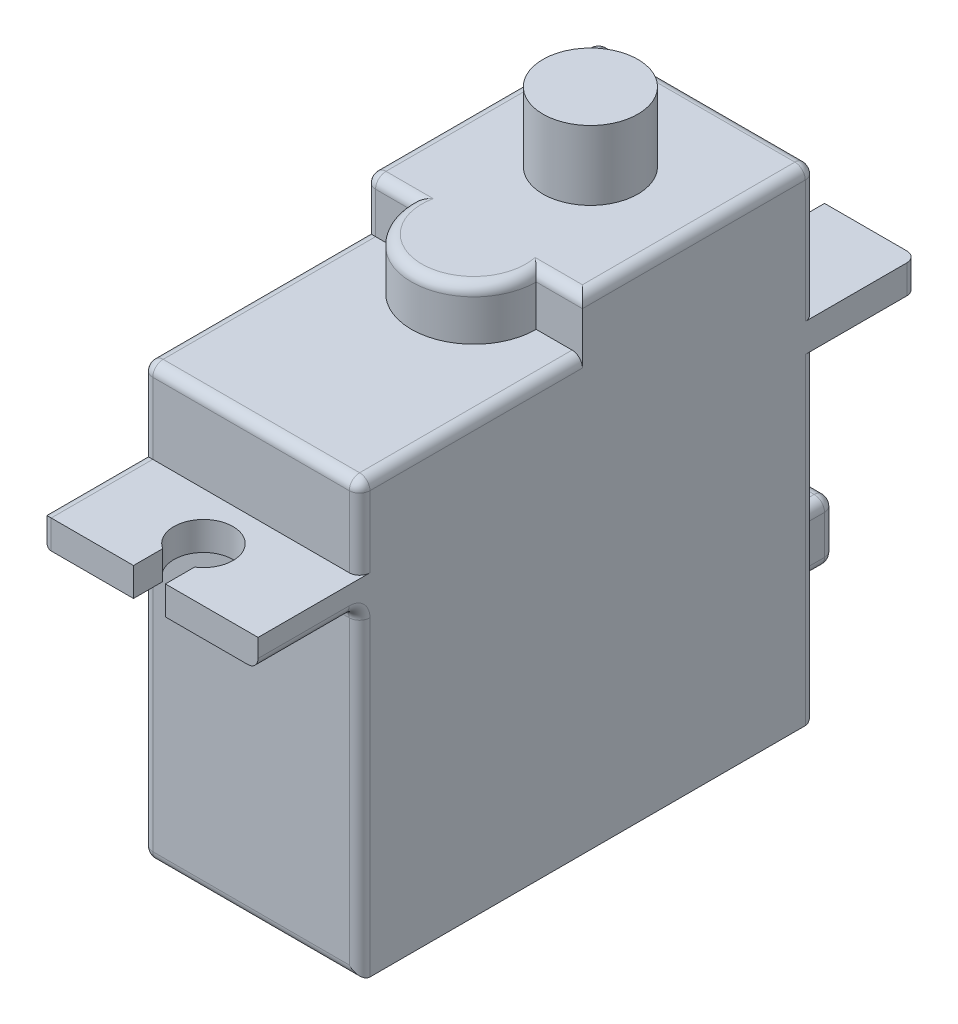
from build123d import *

# Parameters (mm, degrees)
BASE_SKETCH_W           = 13.3096
BASE_SKETCH_H           = 27.94
BASE_DEPTH              = 19.6977
MOUNTING_POINT_SKETCH_W = 13.3096
MOUNTING_POINT_SKETCH_H = 40.386
MOUNTING_POINT_DEPTH    = 1.7526
MOUNTING_HOLES_DEPTH    = 22.4503
MIDDLE_SKETCH_W         = 13.3096
MIDDLE_SKETCH_H         = 27.94
MIDDLE_DEPTH            = 4.9911
TOP_EXTRUDE_DEPTH       = 3.1496
GEAR_SKETCH_R           = 2.9083
GEAR_DEPTH              = 4.2418
SERVO_CABLE_SKETCH_W    = 5.3594
SERVO_CABLE_SKETCH_H    = 3.6576
SEVO_CABLE_DEPTH        = 5.1562
FILLET1_R               = 0.635


with BuildPart() as part:
    # Base Sketch → Base (new body)
    with BuildSketch(Plane(origin=(0, 0, 0), x_dir=(1, 0, 0), z_dir=(0, 1, 0))):
        with Locations((6.6548, 13.97)):
            Rectangle(BASE_SKETCH_W, BASE_SKETCH_H)
    extrude(amount=BASE_DEPTH)

    # Mounting Point Sketch → Mounting Point (add)
    with BuildSketch(Plane(origin=(0, 19.6977, 0), x_dir=(1, 0, 0), z_dir=(0, 1, 0))):
        with Locations((6.6548, 13.97)):
            Rectangle(MOUNTING_POINT_SKETCH_W, MOUNTING_POINT_SKETCH_H)
    extrude(amount=MOUNTING_POINT_DEPTH)

    # Mounting Holes Sketch → Mounting Holes (cut, through all)
    with BuildSketch(Plane(origin=(0, 21.4503, 0), x_dir=(1, 0, 0), z_dir=(0, 1, 0))):
        with BuildLine():
            Line((5.6769, 34.163), (7.6327, 34.163))
            Line((7.6327, 34.163), (7.6327, 32.37744567))
            ThreePointArc((7.6327, 32.37744567), (6.6548, 29.0449), (5.6769, 32.37744567))
            Line((5.6769, 32.37744567), (5.6769, 34.163))
        make_face()
        with BuildLine():
            Line((5.6769, -6.223), (7.6327, -6.223))
            Line((7.6327, -6.223), (7.6327, -4.43744567))
            ThreePointArc((7.6327, -4.43744567), (6.6548, -1.1049), (5.6769, -4.43744567))
            Line((5.6769, -4.43744567), (5.6769, -6.223))
        make_face()
    extrude(amount=-MOUNTING_HOLES_DEPTH, mode=Mode.SUBTRACT)

    # Middle Sketch → Middle (add)
    with BuildSketch(Plane(origin=(0, 21.4503, 0), x_dir=(1, 0, 0), z_dir=(0, 1, 0))):
        with Locations((6.6548, 13.97)):
            Rectangle(MIDDLE_SKETCH_W, MIDDLE_SKETCH_H)
    extrude(amount=MIDDLE_DEPTH)

    # Top Sketch → Top extrude (add)
    with BuildSketch(Plane(origin=(0, 26.4414, 0), x_dir=(1, 0, 0), z_dir=(0, 1, 0))):
        with BuildLine():
            Line((0, 27.94), (13.3096, 27.94))
            Line((13.3096, 27.94), (13.3096, 13.6525))
            Line((13.3096, 13.6525), (10.4775, 13.6525))
            ThreePointArc((10.4775, 13.6525), (6.6548, 9.8298), (2.8321, 13.6525))
            Line((2.8321, 13.6525), (0, 13.6525))
            Line((0, 13.6525), (0, 27.94))
        make_face()
    extrude(amount=TOP_EXTRUDE_DEPTH)

    # Gear Sketch → Gear (add)
    with BuildSketch(Plane(origin=(0, 29.591, 0), x_dir=(1, 0, 0), z_dir=(0, 1, 0))):
        with Locations((6.6548, 20.79625)):
            Circle(GEAR_SKETCH_R)
    extrude(amount=GEAR_DEPTH)

    # Servo Cable Sketch → Sevo Cable (add)
    with BuildSketch(Plane(origin=(0, 0, -27.94), x_dir=(-1, 0, 0), z_dir=(0, 0, -1))):
        with Locations((-6.6548, 5.5626)):
            Rectangle(SERVO_CABLE_SKETCH_W, SERVO_CABLE_SKETCH_H)
    extrude(amount=SEVO_CABLE_DEPTH)

    # Fillet1
    fillet1_edges = [part.edges().sort_by_distance(p)[0] for p in [
        (13.3096, 19.6977, 3.1115),
        (0, 9.84885, -27.94),
        (0, 19.6977, -31.0515),
        (0, 20.574, -34.163),
        (0, 21.4503, -31.0515),
        (0, 25.52065, -27.94),
        (0, 29.591, -20.79625),
        (0, 28.0162, -13.6525),
        (0, 26.4414, -6.82625),
        (0, 23.94585, 0),
        (0, 21.4503, 3.1115),
        (0, 20.574, 6.223),
        (0, 19.6977, 3.1115),
        (0, 0, -13.97),
        (0, 9.84885, 0),
        (6.6548, 19.6977, 0),
        (13.3096, 9.84885, 0),
        (6.6548, 0, 0),
        (9.3345, 5.5626, -33.0962),
        (6.6548, 3.7338, -33.0962),
        (3.9751, 5.5626, -33.0962),
        (6.6548, 7.3914, -33.0962),
        (3.9751, 7.3914, -30.5181),
        (3.9751, 3.7338, -30.5181),
        (9.3345, 3.7338, -30.5181),
        (9.3345, 7.3914, -30.5181),
        (6.6548, 0, -27.94),
        (13.3096, 9.84885, -27.94),
        (13.3096, 29.591, -20.79625),
        (13.3096, 23.94585, 0),
        (6.6548, 26.4414, 0),
        (13.3096, 26.4414, -6.82625),
        (11.89355, 29.591, -13.6525),
        (1.41605, 29.591, -13.6525),
        (6.6548, 29.591, -9.8298),
        (6.6548, 29.591, -27.94),
        (13.3096, 25.52065, -27.94),
        (13.3096, 20.574, -34.163),
    ]]
    fillet(fillet1_edges, radius=FILLET1_R)


solid = part.part
